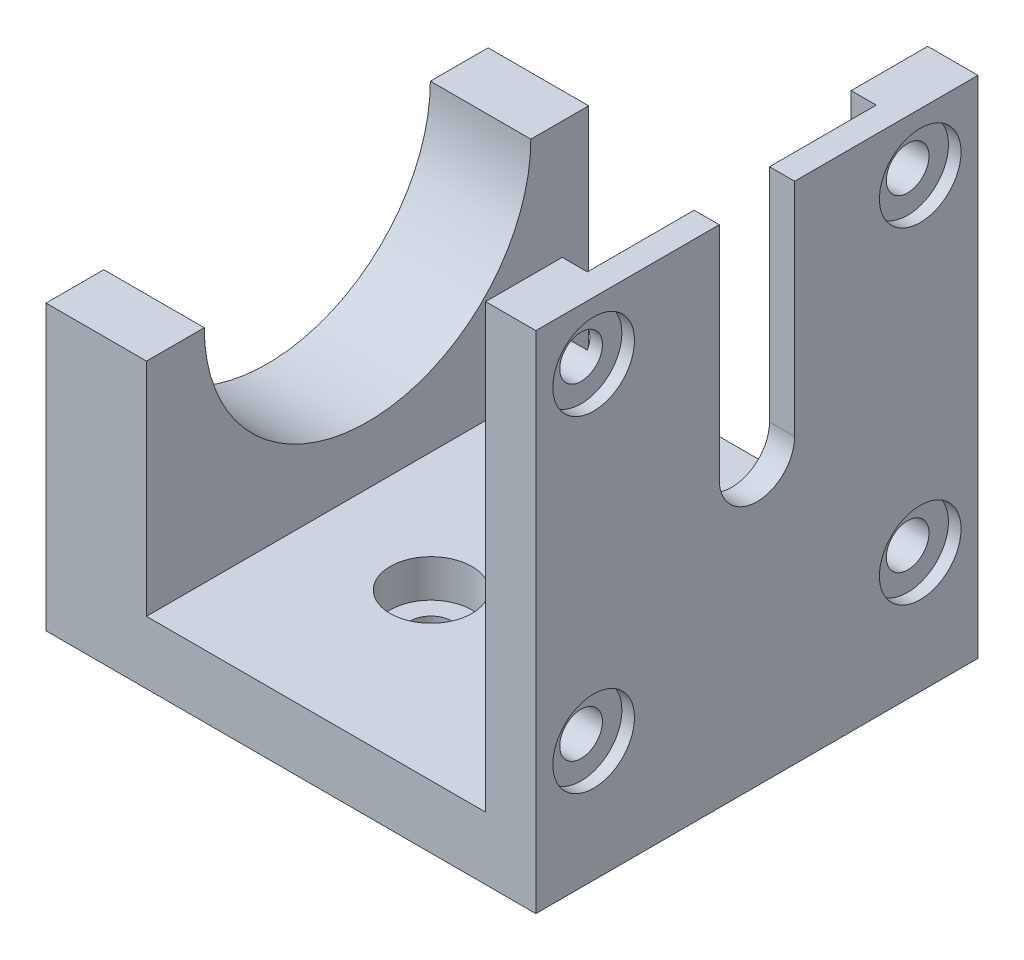
from build123d import *

# Parameters (mm, degrees)
SKETCH1_W                      = 39
SKETCH1_H                      = 35.2
BOSS_EXTRUDE1_DEPTH            = 5
SKETCH2_W                      = 8
SKETCH2_H                      = 35.2
BOSS_EXTRUDE2_DEPTH            = 35.2
SKETCH3_W                      = 4
SKETCH3_H                      = 35.2
BOSS_EXTRUDE3_DEPTH            = 35.2
CUT_EXTRUDE2_REACH             = 41
SKETCH5_R                      = 13
CBORE_FOR_M3_SHCS1_D           = 3.4
CBORE_FOR_M3_SHCS1_DEPTH       = 5
CBORE_FOR_M3_SHCS1_CBORE_D     = 6.5
CBORE_FOR_M3_SHCS1_CBORE_DEPTH = 3
CUT_EXTRUDE3_DEPTH             = 17.6
SKETCH13_R                     = 3
CUT_EXTRUDE5_DEPTH             = 5
SKETCH14_R                     = 11.5
CUT_EXTRUDE6_DEPTH             = 2
CBORE_FOR_M3_SHCS2_D           = 3.4
CBORE_FOR_M3_SHCS2_DEPTH       = 4
CBORE_FOR_M3_SHCS2_CBORE_D     = 6.5
CBORE_FOR_M3_SHCS2_CBORE_DEPTH = 1
SKETCH17_W                     = 8
SKETCH17_H                     = 35.2
CUT_EXTRUDE7_DEPTH             = 17.6


with BuildPart() as part:
    # Sketch1 → Boss-Extrude1 (new body)
    with BuildSketch(Plane(origin=(0, 0, 0), x_dir=(1, 0, 0), z_dir=(0, 1, 0))):
        with Locations((19.5, 17.6)):
            Rectangle(SKETCH1_W, SKETCH1_H)
    extrude(amount=BOSS_EXTRUDE1_DEPTH)

    # Sketch2 → Boss-Extrude2 (add)
    with BuildSketch(Plane(origin=(0, 5, 0), x_dir=(1, 0, 0), z_dir=(0, 1, 0))):
        with Locations((4, 17.6)):
            Rectangle(SKETCH2_W, SKETCH2_H)
    extrude(amount=BOSS_EXTRUDE2_DEPTH)

    # Sketch3 → Boss-Extrude3 (add)
    with BuildSketch(Plane(origin=(0, 5, 0), x_dir=(1, 0, 0), z_dir=(0, 1, 0))):
        with Locations((37, 17.6)):
            Rectangle(SKETCH3_W, SKETCH3_H)
    extrude(amount=BOSS_EXTRUDE3_DEPTH)

    # Sketch5 → Cut-Extrude2 (cut, up to next)
    with BuildSketch(Plane.ZY, mode=Mode.PRIVATE) as cut_extrude2_sk1:
        with Locations((-17.6, 22.6)):
            Circle(SKETCH5_R)
    cut_extrude2_tool1 = extrude(cut_extrude2_sk1.sketch, amount=-CUT_EXTRUDE2_REACH, mode=Mode.PRIVATE) & part.part
    add(cut_extrude2_tool1.solids().sort_by_distance((0, 22.6, -17.6))[0], mode=Mode.SUBTRACT)

    # CBORE for M3 SHCS1
    with Locations(Plane(origin=(0, 5, 0), x_dir=(1, 0, 0), z_dir=(0, 1, 0))):
        with Locations((17.506975999, 13.145005862), (17.500112517, 22.145003245), (26.5, 22.1), (26.5, 13.145005862)):
            CounterBoreHole(CBORE_FOR_M3_SHCS1_D / 2, CBORE_FOR_M3_SHCS1_CBORE_D / 2, CBORE_FOR_M3_SHCS1_CBORE_DEPTH, depth=CBORE_FOR_M3_SHCS1_DEPTH)

    # Sketch10 → Cut-Extrude3 (cut)
    with BuildSketch(Plane(origin=(0, 40.2, 0), x_dir=(1, 0, 0), z_dir=(0, 1, 0))):
        Polygon((37, 20.6), (39, 20.6), (39, 14.6), (37, 14.6), (37, 6.1), (35, 6.1), (35, 29.1), (37, 29.1), align=None)
    extrude(amount=-CUT_EXTRUDE3_DEPTH, mode=Mode.SUBTRACT)

    # Sketch13 → Cut-Extrude5 (cut, through all)
    with BuildSketch(Plane.ZY.offset(-35)):
        with Locations((-17.6, 22.6)):
            Circle(SKETCH13_R)
    extrude(amount=-CUT_EXTRUDE5_DEPTH, mode=Mode.SUBTRACT)

    # Sketch14 → Cut-Extrude6 (cut)
    with BuildSketch(Plane.ZY.offset(-35)):
        with Locations((-17.6, 22.6)):
            Circle(SKETCH14_R)
    extrude(amount=-CUT_EXTRUDE6_DEPTH, mode=Mode.SUBTRACT)

    # CBORE for M3 SHCS2
    with Locations(Plane(origin=(39, 0, 0), x_dir=(0, 0, -1), z_dir=(1, 0, 0))):
        with Locations((30.6, 35.6), (30.6, 9.6), (4.6, 9.6), (4.6, 35.6)):
            CounterBoreHole(CBORE_FOR_M3_SHCS2_D / 2, CBORE_FOR_M3_SHCS2_CBORE_D / 2, CBORE_FOR_M3_SHCS2_CBORE_DEPTH, depth=CBORE_FOR_M3_SHCS2_DEPTH)

    # Sketch17 → Cut-Extrude7 (cut)
    with BuildSketch(Plane(origin=(0, 40.2, 0), x_dir=(1, 0, 0), z_dir=(0, 1, 0))):
        with Locations((4, 17.6)):
            Rectangle(SKETCH17_W, SKETCH17_H)
    extrude(amount=-CUT_EXTRUDE7_DEPTH, mode=Mode.SUBTRACT)


solid = part.part
